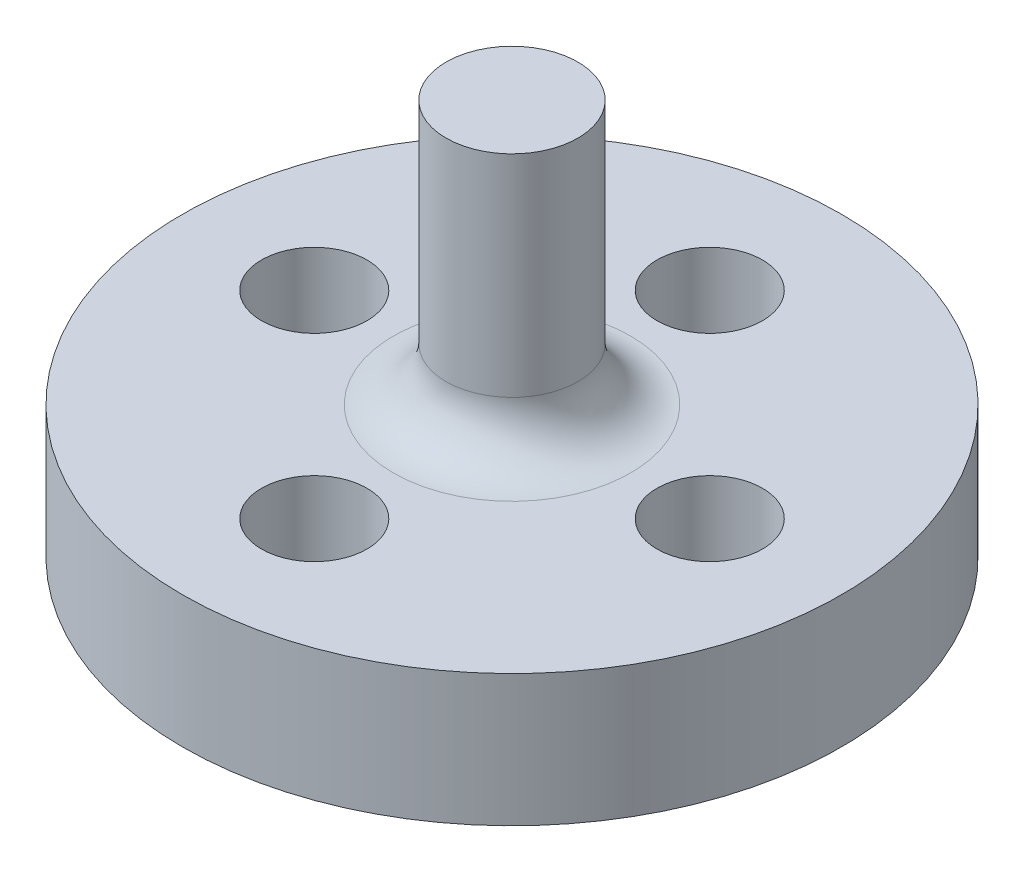
from build123d import *

# Parameters (mm, degrees)
SKETCH1_R           = 12.5
SKETCH1_R_2         = 2
BOSS_EXTRUDE1_DEPTH = 5
SKETCH2_R           = 2.5
BOSS_EXTRUDE2_DEPTH = 10
SKETCH3_R           = 5
CUT_EXTRUDE1_DEPTH  = 2
FILLET2_R           = 2


with BuildPart() as part:
    # Sketch1 → Boss-Extrude1 (new body)
    with BuildSketch(Plane(origin=(0, 0, 0), x_dir=(1, 0, 0), z_dir=(0, 1, 0))):
        Circle(SKETCH1_R)
        with Locations((-7.5, 0)):
            Circle(SKETCH1_R_2, mode=Mode.SUBTRACT)
        with Locations((0, 7.5)):
            Circle(SKETCH1_R_2, mode=Mode.SUBTRACT)
        with Locations((7.5, 0)):
            Circle(SKETCH1_R_2, mode=Mode.SUBTRACT)
        with Locations((0, -7.5)):
            Circle(SKETCH1_R_2, mode=Mode.SUBTRACT)
    extrude(amount=BOSS_EXTRUDE1_DEPTH)

    # Sketch2 → Boss-Extrude2 (add)
    with BuildSketch(Plane(origin=(0, 5, 0), x_dir=(1, 0, 0), z_dir=(0, 1, 0))):
        Circle(SKETCH2_R)
    extrude(amount=BOSS_EXTRUDE2_DEPTH)

    # Sketch3 → Cut-Extrude1 (cut)
    with BuildSketch(Plane.XZ):
        Circle(SKETCH3_R)
    extrude(amount=-CUT_EXTRUDE1_DEPTH, mode=Mode.SUBTRACT)

    # Fillet2
    fillet2_edges = [part.edges().sort_by_distance(p)[0] for p in [
        (-2.5, 5, 0),
    ]]
    fillet(fillet2_edges, radius=FILLET2_R)


solid = part.part
